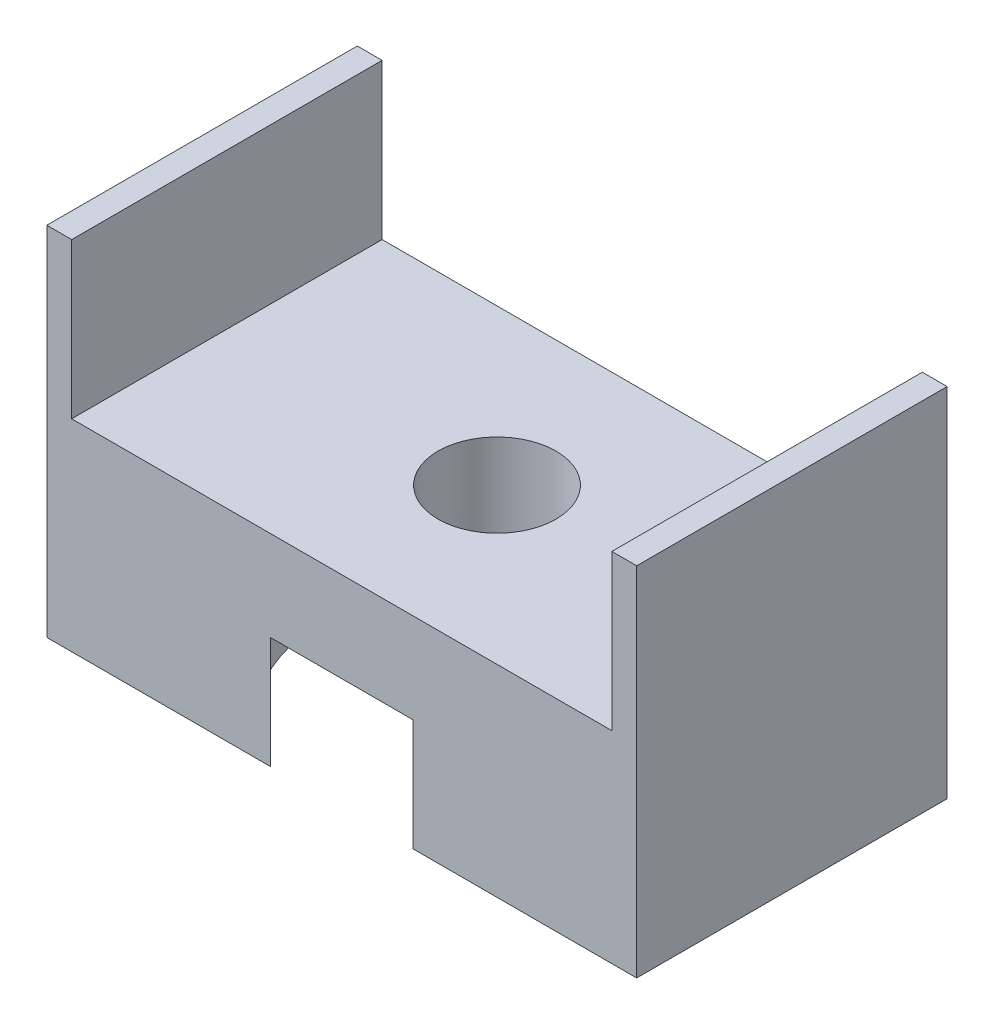
from build123d import *

# Parameters (mm, degrees)
SKETCH2_W           = 24.13
SKETCH2_H           = 12.7
SKETCH2_R           = 2.413
BOSS_EXTRUDE1_DEPTH = 8.255
SKETCH3_W           = 1.016
SKETCH3_H           = 12.7
BOSS_EXTRUDE2_DEPTH = 6.35
SKETCH4_R           = 6.985
CUT_EXTRUDE1_DEPTH  = 4.572
SKETCH5_W           = 1.016
SKETCH5_H           = 12.7
BOSS_EXTRUDE3_DEPTH = 6.35


with BuildPart() as part:
    # Sketch2 → Boss-Extrude1 (new body)
    with BuildSketch(Plane(origin=(0, 0, 0), x_dir=(1, 0, 0), z_dir=(0, 1, 0))):
        with Locations((12.223927374, 7.715072626)):
            Rectangle(SKETCH2_W, SKETCH2_H)
        with Locations(Location((12.223927374, 7.715072626, 0), (0, 0, 270))):  # turned: the seam where the file's is
            Circle(SKETCH2_R, mode=Mode.SUBTRACT)
    extrude(amount=BOSS_EXTRUDE1_DEPTH)

    # Sketch3 → Boss-Extrude2 (add)
    with BuildSketch(Plane(origin=(0, 8.255, 0), x_dir=(1, 0, 0), z_dir=(0, 1, 0))):
        with Locations((0.666927374, 7.715072626)):
            Rectangle(SKETCH3_W, SKETCH3_H)
    extrude(amount=BOSS_EXTRUDE2_DEPTH)

    # Sketch4 → Cut-Extrude1 (cut)
    with BuildSketch(Plane.XZ):
        with Locations((12.223927374, -7.715072626)):
            Circle(SKETCH4_R)
    extrude(amount=-CUT_EXTRUDE1_DEPTH, mode=Mode.SUBTRACT)

    # Sketch5 → Boss-Extrude3 (add)
    with BuildSketch(Plane(origin=(0, 8.255, 0), x_dir=(1, 0, 0), z_dir=(0, 1, 0))):
        with Locations((23.780927374, 7.715072626)):
            Rectangle(SKETCH5_W, SKETCH5_H)
    extrude(amount=BOSS_EXTRUDE3_DEPTH)


solid = part.part
